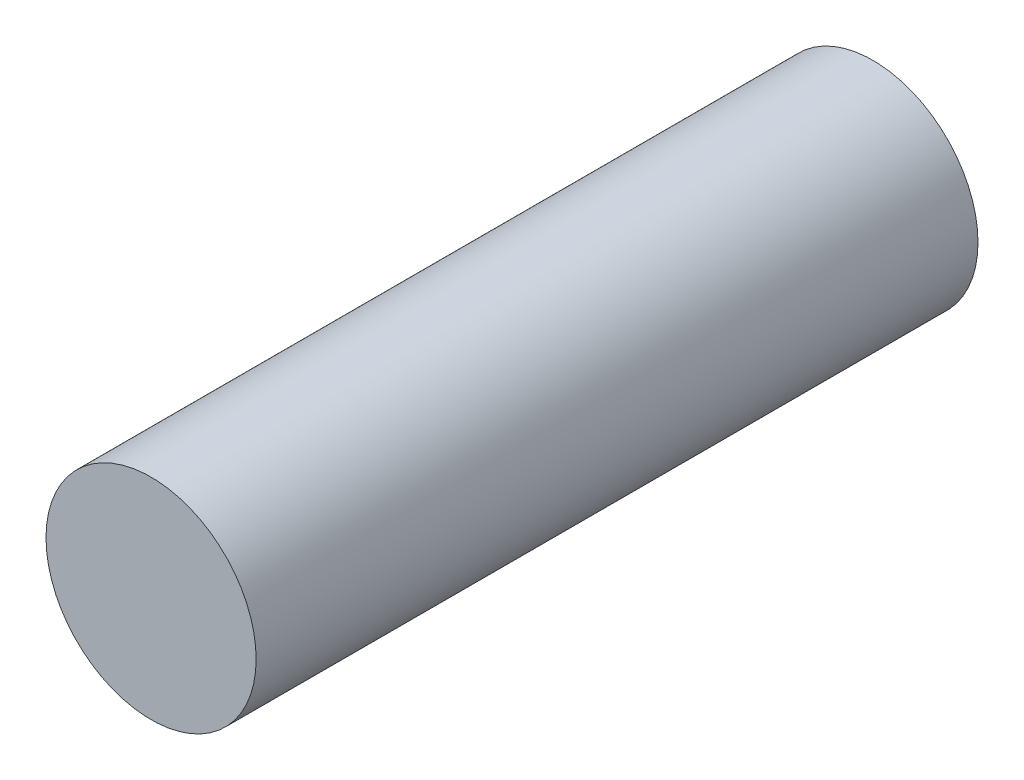
from build123d import *

# Parameters (mm, degrees)
SKETCH1_R           = 2.5
BOSS_EXTRUDE1_DEPTH = 17.175


with BuildPart() as part:
    # Sketch1 → Boss-Extrude1 (new body)
    with BuildSketch(Plane.XY):
        Circle(SKETCH1_R)
    extrude(amount=BOSS_EXTRUDE1_DEPTH)


solid = part.part
